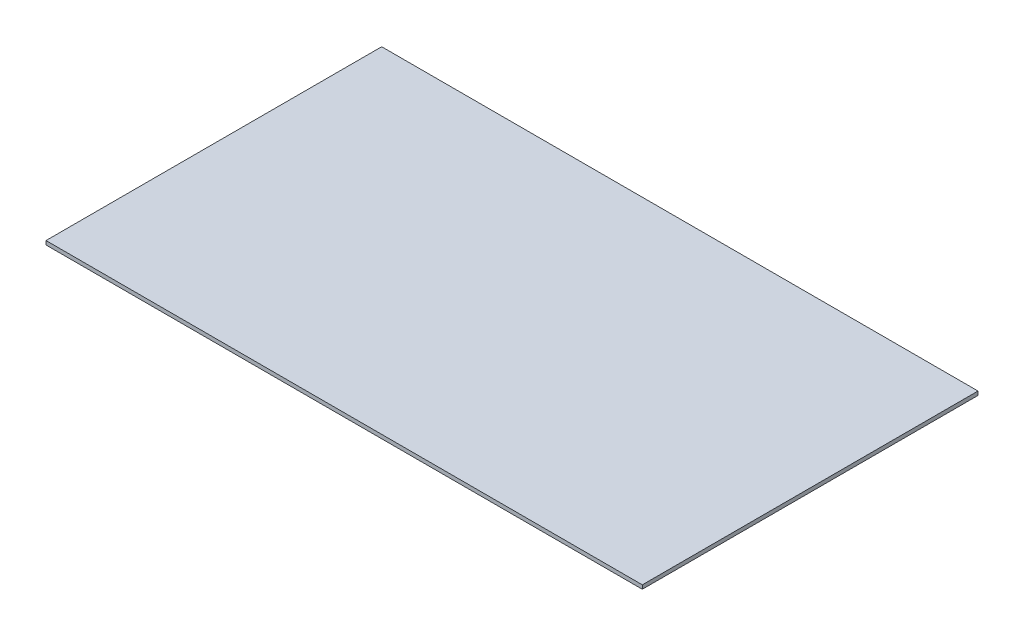
from build123d import *

# Parameters (mm, degrees)
SKETCH1_W           = 57.2
SKETCH1_H           = 32.2
BOSS_EXTRUDE1_DEPTH = 0.37


with BuildPart() as part:
    # Sketch1 → Boss-Extrude1 (new body)
    with BuildSketch(Plane(origin=(0, 0, 0), x_dir=(1, 0, 0), z_dir=(0, 1, 0))):
        with Locations((-3.790361446, 2.507228916)):
            Rectangle(SKETCH1_W, SKETCH1_H)
    extrude(amount=BOSS_EXTRUDE1_DEPTH)


solid = part.part
